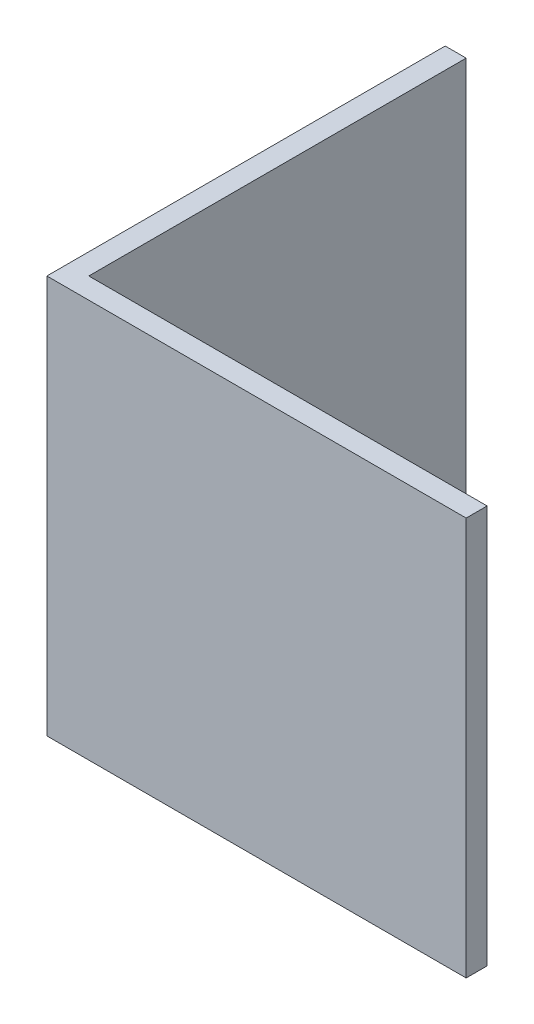
from build123d import *

# Parameters (mm, degrees)
EXTRUDE_1_DEPTH     = 19
SKETCH_4_W          = 1
SKETCH_4_H          = 19
CUT_EXTRUDE_2_DEPTH = 1


with BuildPart() as part:
    # Эскиз1 → Бобышка-Вытянуть1 (new body)
    with BuildSketch(Plane(origin=(0, 0, 0), x_dir=(1, 0, 0), z_dir=(0, 1, 0))):
        Polygon((0, 0), (0, 20), (1, 20), (1, 1), (20, 1), (20, 0), align=None)
    extrude(amount=EXTRUDE_1_DEPTH)

    # Эскиз4 → Вырез-Вытянуть2 (cut)
    with BuildSketch(Plane(origin=(0, 0, -20), x_dir=(-1, 0, 0), z_dir=(0, 0, -1))):
        with Locations((-0.5, 9.5)):
            Rectangle(SKETCH_4_W, SKETCH_4_H)
    extrude(amount=-CUT_EXTRUDE_2_DEPTH, mode=Mode.SUBTRACT)


solid = part.part
